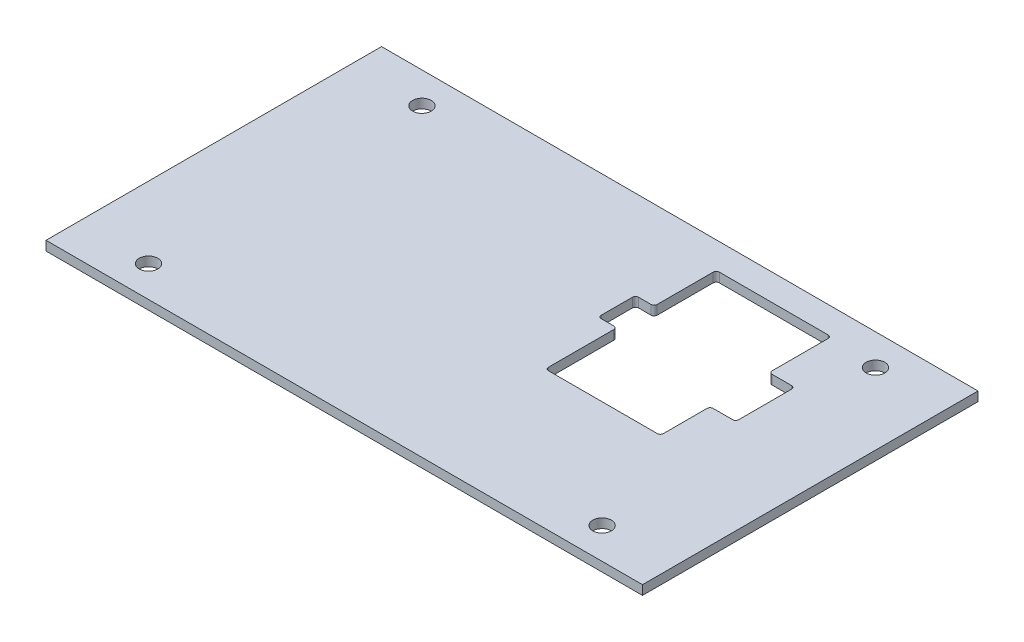
from build123d import *

# Parameters (mm, degrees)
SKETCH_1_W          = 192
SKETCH_1_H          = 108
EXTRUDE_1_DEPTH     = 3
SKETCH_2_R          = 3
CUT_EXTRUDE_1_DEPTH = 4
FILLET_1_R          = 1


with BuildPart() as part:
    # Эскиз1 → Бобышка-Вытянуть1 (new body)
    with BuildSketch(Plane(origin=(0, 0, 0), x_dir=(1, 0, 0), z_dir=(0, 1, 0))):
        Rectangle(SKETCH_1_W, SKETCH_1_H)
    extrude(amount=EXTRUDE_1_DEPTH)

    # Эскиз2 → Вырез-Вытянуть1 (cut, through all)
    with BuildSketch(Plane(origin=(0, 3, 0), x_dir=(1, 0, 0), z_dir=(0, 1, 0))):
        with Locations((-73, 44)):
            Circle(SKETCH_2_R)
        with Locations((73, 44)):
            Circle(SKETCH_2_R)
        with Locations((-73, -44)):
            Circle(SKETCH_2_R)
        with Locations((73, -44)):
            Circle(SKETCH_2_R)
        Polygon((20.25, 45.5), (20.25, 25.5), (14.25, 25.5), (14.25, 13.5), (20.25, 13.5), (20.25, -9.5), (57.25, -9.5), (57.25, 6.5), (65.5, 6.5), (65.5, 25.5), (57.25, 25.5), (57.25, 45.5), align=None)
    extrude(amount=-CUT_EXTRUDE_1_DEPTH, mode=Mode.SUBTRACT)

    # Скругление1
    fillet_1_edges = [part.edges().sort_by_distance(p)[0] for p in [
        (20.25, 1.5, -45.5),
        (57.25, 1.5, -45.5),
        (57.25, 1.5, -25.5),
        (65.5, 1.5, -25.5),
        (65.5, 1.5, -6.5),
        (57.25, 1.5, -6.5),
        (57.25, 1.5, 9.5),
        (20.25, 1.5, 9.5),
        (20.25, 1.5, -13.5),
        (14.25, 1.5, -13.5),
        (14.25, 1.5, -25.5),
        (20.25, 1.5, -25.5),
    ]]
    fillet(fillet_1_edges, radius=FILLET_1_R)


solid = part.part
